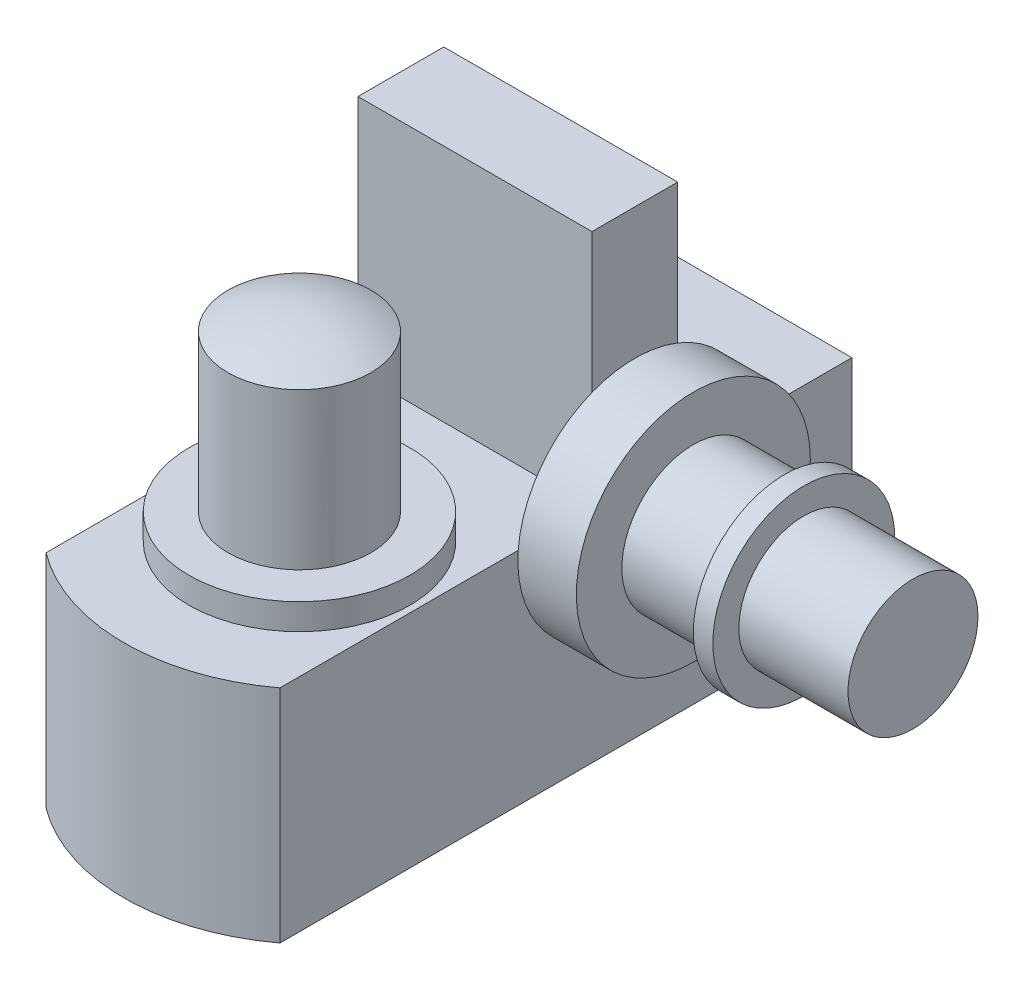
from build123d import *

# Parameters (mm, degrees)
BOSS_EXTRUDE1_DEPTH = 42.5
SKETCH3_R           = 42.5
BOSS_EXTRUDE2_DEPTH = 10
SKETCH4_R           = 27.5
BOSS_EXTRUDE3_DEPTH = 60
SKETCH6_W           = 90
SKETCH6_H           = 33
BOSS_EXTRUDE4_DEPTH = 92
SKETCH7_R           = 45
BOSS_EXTRUDE5_DEPTH = 22.5
SKETCH9_R           = 27.5
BOSS_EXTRUDE6_DEPTH = 35
SKETCH10_R          = 35
BOSS_EXTRUDE7_DEPTH = 7.5
SKETCH11_R          = 25
BOSS_EXTRUDE8_DEPTH = 42


with BuildPart() as part:
    # Sketch2 → Boss-Extrude1 (new, symmetric)
    with BuildSketch(Plane(origin=(0, 0, 0), x_dir=(1, 0, 0), z_dir=(0, 1, 0))):
        with BuildLine():
            Line((-45, 60), (-45, 160))
            Line((-45, 160), (45, 160))
            Line((45, 160), (45, 60))
            Line((45, 60), (45, -60))
            ThreePointArc((45, -60), (0, -75), (-45, -60))
            Line((-45, -60), (-45, 60))
        make_face()
    extrude(amount=BOSS_EXTRUDE1_DEPTH, both=True)

    # Sketch3 → Boss-Extrude2 (add)
    with BuildSketch(Plane(origin=(0, 42.5, 0), x_dir=(1, 0, 0), z_dir=(0, 1, 0))):
        with Locations((0, -7.5)):
            Circle(SKETCH3_R)
    extrude(amount=BOSS_EXTRUDE2_DEPTH)

    # Sketch4 → Boss-Extrude3 (add)
    with BuildSketch(Plane(origin=(0, 52.5, 0), x_dir=(1, 0, 0), z_dir=(0, 1, 0))):
        with Locations((0, -7.5)):
            Circle(SKETCH4_R)
    extrude(amount=BOSS_EXTRUDE3_DEPTH)

    # Sketch5 → Revolve1 (revolve)
    with BuildSketch(Plane(origin=(0, 0, 0), x_dir=(0, 0, -1), z_dir=(1, 0, 0))):
        with BuildLine():
            Line((-35, 112.5), (-7.5, 112.5))
            Line((-7.5, 112.5), (-7.5, 119.173177481))
            ThreePointArc((-7.5, 119.173177481), (-21.6490397, 117.481021512), (-35, 112.5))
        make_face()
    revolve(axis=Axis((0, 112.5, 7.5), (0, 1, 0)))

    # Sketch6 → Boss-Extrude4 (add)
    with BuildSketch(Plane(origin=(0, 42.5, 0), x_dir=(1, 0, 0), z_dir=(0, 1, 0))):
        with Locations((0, 76.5)):
            Rectangle(SKETCH6_W, SKETCH6_H)
    extrude(amount=BOSS_EXTRUDE4_DEPTH)

    # Sketch7 → Boss-Extrude5 (add)
    with BuildSketch(Plane(origin=(45, 0, 0), x_dir=(0, 0, -1), z_dir=(1, 0, 0))):
        with Locations((76.5, 39.052114436)):
            Circle(SKETCH7_R)
    extrude(amount=BOSS_EXTRUDE5_DEPTH)

    # Sketch9 → Boss-Extrude6 (add)
    with BuildSketch(Plane(origin=(67.5, 0, 0), x_dir=(0, 0, -1), z_dir=(1, 0, 0))):
        with Locations((76.5, 39.052114436)):
            Circle(SKETCH9_R)
    extrude(amount=BOSS_EXTRUDE6_DEPTH)

    # Sketch10 → Boss-Extrude7 (add)
    with BuildSketch(Plane(origin=(102.5, 0, 0), x_dir=(0, 0, -1), z_dir=(1, 0, 0))):
        with Locations((76.5, 39.052114436)):
            Circle(SKETCH10_R)
    extrude(amount=BOSS_EXTRUDE7_DEPTH)

    # Sketch11 → Boss-Extrude8 (add)
    with BuildSketch(Plane(origin=(110, 0, 0), x_dir=(0, 0, -1), z_dir=(1, 0, 0))):
        with Locations((76.5, 39.052114436)):
            Circle(SKETCH11_R)
    extrude(amount=BOSS_EXTRUDE8_DEPTH)


solid = part.part
